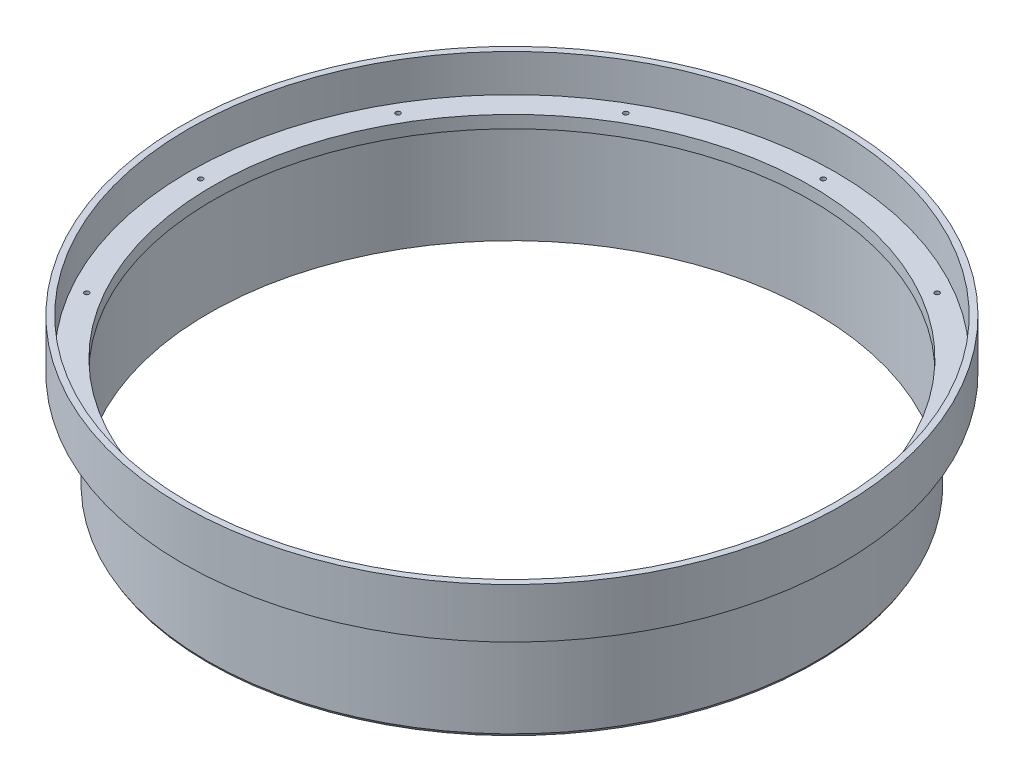
from build123d import *

# Parameters (mm, degrees)
SCREW_HOLES_COUNT = 12


with BuildPart() as part:
    # Cross Section → Main (revolve)
    with BuildSketch(Plane.XY):
        Polygon((-76.2, 0), (-76.2, -3.175), (-77.216, -3.175), (-77.216, -28.575), (-77.597, -27.915088642), (-77.597, -3.175), (-83.947, -3.175), (-83.947, 9.525), (-82.3595, 9.525), (-82.3595, 0), align=None)
    revolve(axis=Axis((0, 55, 0), (0, -1, 0)))

    # Sketch7 → #0-80 Tapped Hole1 (revolve, cut)
    with BuildSketch(Plane(origin=(-79.27975, 0, 0), x_dir=(0, 0, 1), z_dir=(1, 0, 0))):
        Polygon((0, 0), (0, 2.897890611), (0.59563, 2.54), (0.59563, 0), align=None)
    f_0_80_tapped_hole1 = revolve(axis=Axis((-79.27975, 6.35, 0), (0, -1, 0)), mode=Mode.SUBTRACT)

    # Screw Holes: #0-80 Tapped Hole1 ×12 about axis
    screw_holes_axis = Axis((0, 0, 0), (0, 1, 0))
    for i in range(1, SCREW_HOLES_COUNT):
        add(f_0_80_tapped_hole1.rotate(screw_holes_axis, i * 360 / SCREW_HOLES_COUNT), mode=Mode.SUBTRACT)


solid = part.part
